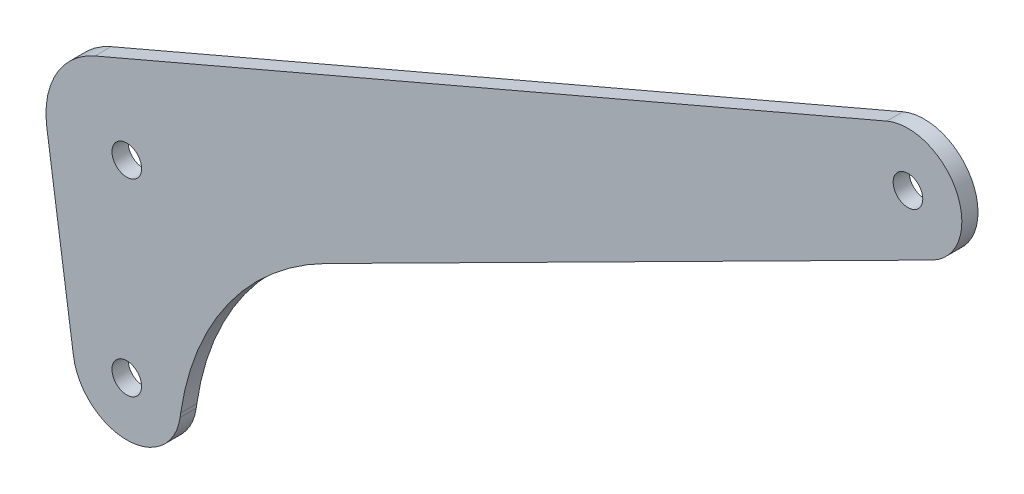
from build123d import *

# Parameters (mm, degrees)
ESQUISSE4_R        = 10
ESQUISSE4_R_2      = 15
BOSS_EXTRU_1_DEPTH = 3
D_GAGEMENT_M51_D   = 5.5


with BuildPart() as part:
    # Esquisse4 → Boss.-Extru.1 (new body)
    with BuildSketch(Plane.XY):
        with Locations((145.009245926, 102.618921879)):
            Circle(ESQUISSE4_R)
        with BuildLine():
            Line((36.96319164, 36.860248406), (149.516585657, 93.692338627))
            ThreePointArc((149.516585657, 93.692338627), (135.946168055, 98.392739261), (141.068348562, 111.809641544))
            Line((141.068348562, 111.809641544), (-5.911346046, 48.786079498))
            ThreePointArc((-5.911346046, 48.786079498), (8.25620401, 47.523381945), (15, 35))
            ThreePointArc((15, 35), (14.961488006, 33.925813491), (14.846149779, 32.857142857))
            Line((14.846149779, 32.857142857), (13.730743914, 25.129384342))
            Line((13.730743914, 25.129384342), (36.96319164, 36.860248406))
        make_face()
        with Locations((0, 35)):
            Circle(ESQUISSE4_R_2)
        with BuildLine():
            Line((10.012724365, -0.629810709), (13.730743914, 25.129384342))
            Line((13.730743914, 25.129384342), (6.761009597, 21.610125123))
            ThreePointArc((6.761009597, 21.610125123), (-6.925765295, 21.69459602), (-14.846149779, 32.857142857))
            Line((-14.846149779, 32.857142857), (-9.897433186, -1.428571429))
            ThreePointArc((-9.897433186, -1.428571429), (-0.716124339, 9.974325337), (10, 0))
            ThreePointArc((10, 0), (9.974325337, -0.716124339), (9.897433186, -1.428571429))
            Line((9.897433186, -1.428571429), (10.012724365, -0.629810709))
        make_face()
        Circle(ESQUISSE4_R)
        with BuildLine():
            ThreePointArc((10.012724365, -0.629810709), (18.9014248, 21.412338562), (36.96319164, 36.860248406))
            Line((36.96319164, 36.860248406), (13.730743914, 25.129384342))
            Line((13.730743914, 25.129384342), (10.012724365, -0.629810709))
        make_face()
        with BuildLine():
            Line((6.761009597, 21.610125123), (13.730743914, 25.129384342))
            Line((13.730743914, 25.129384342), (14.846149779, 32.857142857))
            ThreePointArc((14.846149779, 32.857142857), (12.179539649, 26.244498076), (6.761009597, 21.610125123))
        make_face()
    extrude(amount=BOSS_EXTRU_1_DEPTH)

    # Dégagement M51 (through all)
    with Locations(Plane(origin=(0, 0, 3), x_dir=(-1, 0, 0), z_dir=(0, 0, 1))):
        with Locations((-145.009245926, -102.618921879), (0, -35), (0, 0)):
            Hole(D_GAGEMENT_M51_D / 2)


solid = part.part
